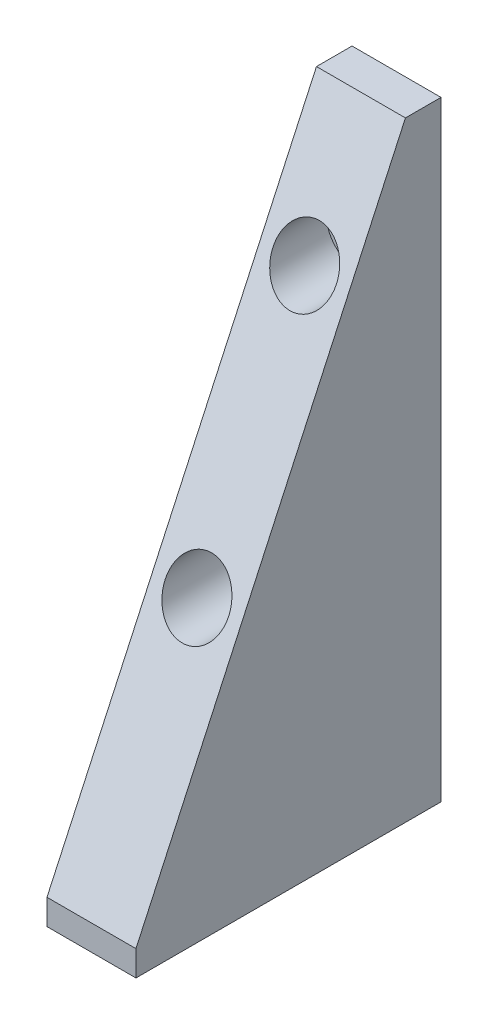
from build123d import *

# Parameters (mm, degrees)
BOSS_EXTRUDE2_DEPTH         = 22.225
CUT_EXTRUDE2_REACH          = 59.15
SKETCH7_R                   = 7.9375
F_3_8_16_TAPPED_HOLE1_D     = 7.9375
F_3_8_16_TAPPED_HOLE1_DEPTH = 25.4
F_3_8_16_TAPPED_HOLE1_TIP   = 2.384665582


with BuildPart() as part:
    # Sketch1 → Boss-Extrude2 (new body)
    with BuildSketch(Plane(origin=(0, 0, 0), x_dir=(0, 0, -1), z_dir=(1, 0, 0))):
        Polygon((21.525976172, 126.619), (-45.784023828, -19.431), (-45.784023828, -25.781), (30.415976172, -25.781), (30.415976172, 126.619), align=None)
    extrude(amount=BOSS_EXTRUDE2_DEPTH)

    # Sketch4 → CBORE for 3/8 Socket Head Cap Screw1 (revolve, cut)
    with BuildSketch(Plane(origin=(11.1125, 96.139, -11.365976172), x_dir=(0, -1, 0), z_dir=(1, 0, 0))):
        Polygon((0, 0), (0, 19.05), (4.9022, 19.05), (4.9022, 9.525), (7.9375, 9.525), (7.9375, 0), align=None)
    revolve(axis=Axis((11.1125, 96.139, -5.015976172), (0, 0, -1)), mode=Mode.SUBTRACT)

    # Sketch6 → CBORE for 3/8 Socket Head Cap Screw2 (revolve, cut)
    with BuildSketch(Plane(origin=(11.1125, 37.719, -10.095976172), x_dir=(0, -1, 0), z_dir=(1, 0, 0))):
        Polygon((0, 0), (0, 20.32), (4.9022, 20.32), (4.9022, 9.525), (7.9375, 9.525), (7.9375, 0), align=None)
    revolve(axis=Axis((11.1125, 37.719, -3.745976172), (0, 0, -1)), mode=Mode.SUBTRACT)

    # Sketch7 → Cut-Extrude2 (cut, up to next)
    with BuildSketch(Plane(origin=(0, 96.139, -11.365976172), x_dir=(1, 0, 0), z_dir=(0, 0, 1)), mode=Mode.PRIVATE) as cut_extrude2_sk1:
        with Locations((11.1125, -58.42)):
            Circle(SKETCH7_R)
    cut_extrude2_tool1 = extrude(cut_extrude2_sk1.sketch, amount=CUT_EXTRUDE2_REACH, mode=Mode.PRIVATE) & part.part
    add(cut_extrude2_tool1.solids().sort_by_distance((11.1125, 37.719, -11.365976))[0], mode=Mode.SUBTRACT)
    # Sketch7 → Cut-Extrude2 (cut, up to next)
    with BuildSketch(Plane(origin=(0, 96.139, -11.365976172), x_dir=(1, 0, 0), z_dir=(0, 0, 1)), mode=Mode.PRIVATE) as cut_extrude2_sk2:
        with Locations((11.1125, 0)):
            Circle(SKETCH7_R)
    cut_extrude2_tool2 = extrude(cut_extrude2_sk2.sketch, amount=CUT_EXTRUDE2_REACH, mode=Mode.PRIVATE) & part.part
    add(cut_extrude2_tool2.solids().sort_by_distance((11.1125, 96.139, -11.365976))[0], mode=Mode.SUBTRACT)

    # 3/8-16 Tapped Hole1
    with Locations(Plane(origin=(11.1125, -25.781, -15.175976172), x_dir=(0, 0, -1), z_dir=(0, -1, 0))):
        with Locations((0, 0), (-40.64, 0)):
            Hole(F_3_8_16_TAPPED_HOLE1_D / 2, depth=F_3_8_16_TAPPED_HOLE1_DEPTH)
            with Locations((0, 0, -(F_3_8_16_TAPPED_HOLE1_DEPTH + F_3_8_16_TAPPED_HOLE1_TIP / 2))):  # 118° drill point
                Cone(0, F_3_8_16_TAPPED_HOLE1_D / 2, F_3_8_16_TAPPED_HOLE1_TIP, mode=Mode.SUBTRACT)


solid = part.part
